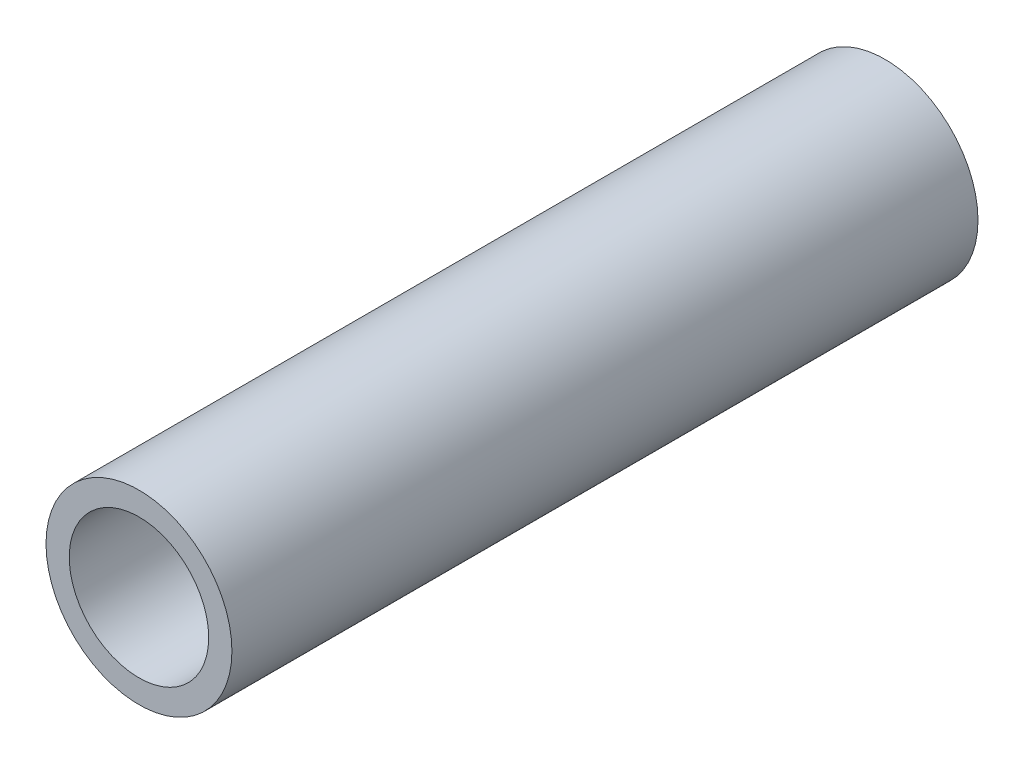
from build123d import *

# Parameters (mm, degrees)
SKETCH2_R           = 4.233333333
SKETCH2_R_2         = 3.175
BOSS_EXTRUDE1_DEPTH = 33.9725


with BuildPart() as part:
    # Sketch2 → Boss-Extrude1 (new body)
    with BuildSketch(Plane.XY):
        Circle(SKETCH2_R)
        Circle(SKETCH2_R_2, mode=Mode.SUBTRACT)
    extrude(amount=BOSS_EXTRUDE1_DEPTH)


solid = part.part
